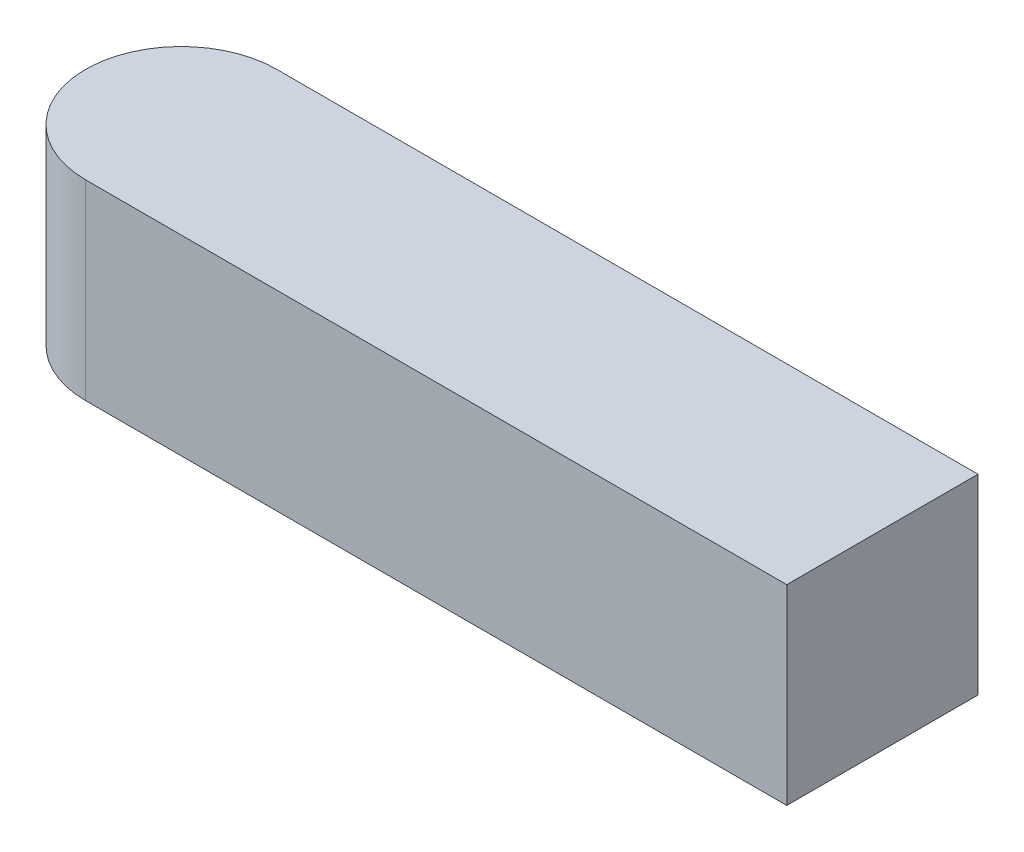
from build123d import *

# Parameters (mm, degrees)
BOSS_EXTRUDE1_DEPTH = 12
SKETCH2_W           = 50
SKETCH2_H           = 12
CUT_EXTRUDE1_DEPTH  = 13


with BuildPart() as part:
    # Sketch1 → Boss-Extrude1 (new body)
    with BuildSketch(Plane(origin=(0, 0, 0), x_dir=(1, 0, 0), z_dir=(0, 1, 0))):
        with BuildLine():
            Line((-44, 6), (44, 6))
            ThreePointArc((44, 6), (50, 0), (44, -6))
            Line((44, -6), (-44, -6))
            ThreePointArc((-44, -6), (-50, 0), (-44, 6))
        make_face()
    extrude(amount=BOSS_EXTRUDE1_DEPTH)

    # Sketch2 → Cut-Extrude1 (cut, through all)
    with BuildSketch(Plane(origin=(0, 12, 0), x_dir=(1, 0, 0), z_dir=(0, 1, 0))):
        with Locations((25, 0)):
            Rectangle(SKETCH2_W, SKETCH2_H)
    extrude(amount=-CUT_EXTRUDE1_DEPTH, mode=Mode.SUBTRACT)


solid = part.part
